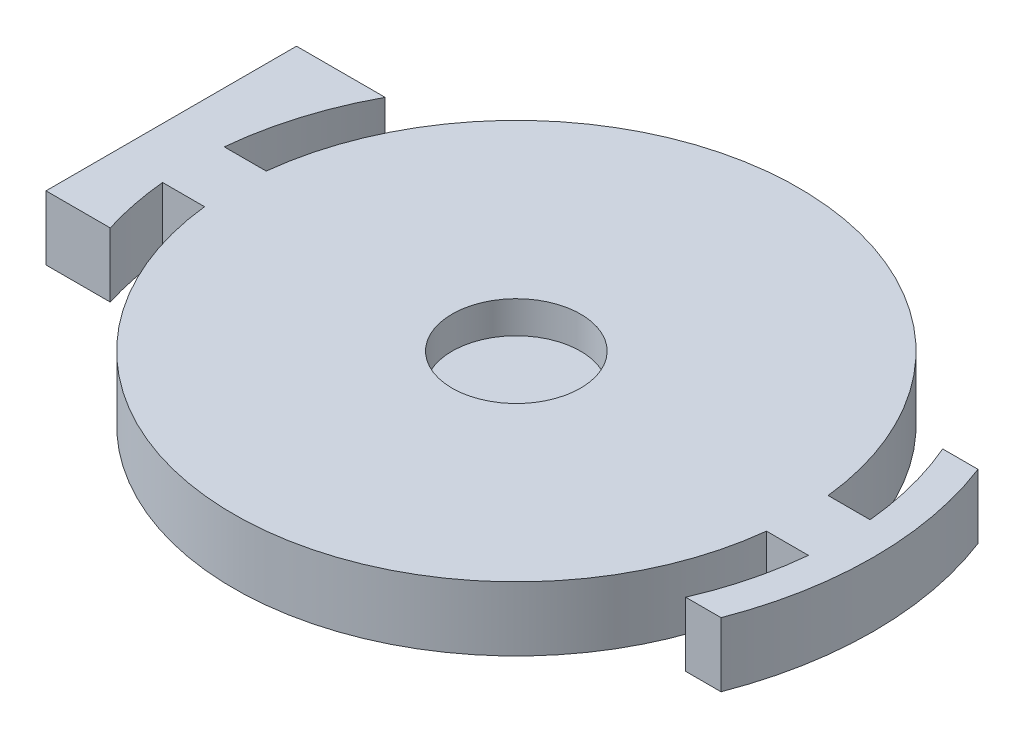
from build123d import *

# Parameters (mm, degrees)
SKETCH1_R           = 22
SKETCH1_W           = 4
SKETCH1_H           = 4.8
BOSS_EXTRUDE1_DEPTH = 5
BOSS_EXTRUDE2_DEPTH = 5
SKETCH3_R           = 5
CUT_EXTRUDE1_DEPTH  = 2.5


with BuildPart() as part:
    # Sketch1 → Boss-Extrude1 (new body)
    with BuildSketch(Plane(origin=(0, 0, 0), x_dir=(1, 0, 0), z_dir=(0, 1, 0))):
        Circle(SKETCH1_R)
        with Locations((-23.868699093, 0)):
            Rectangle(SKETCH1_W, SKETCH1_H)
        with BuildLine():
            Line((21.868699093, 2.4), (25.135681809, 2.4))
            ThreePointArc((25.135681809, 2.4), (24.45754678, 6.276217454), (23.185394109, 10))
            Line((23.185394109, 10), (25.935394109, 10))
            ThreePointArc((25.935394109, 10), (27.796486605, 0), (25.935394109, -10))
            Line((25.935394109, -10), (23.185394109, -10))
            ThreePointArc((23.185394109, -10), (24.45754678, -6.276217454), (25.135681809, -2.4))
            Line((25.135681809, -2.4), (21.868699093, -2.4))
            Line((21.868699093, -2.4), (21.868699093, 2.4))
        make_face()
    extrude(amount=BOSS_EXTRUDE1_DEPTH)

    # Sketch2 → Boss-Extrude2 (add)
    with BuildSketch(Plane(origin=(0, 5, 0), x_dir=(1, 0, 0), z_dir=(0, 1, 0))):
        with BuildLine():
            Line((-29.110423057, 12), (-22.216266563, 12))
            ThreePointArc((-22.216266563, 12), (-25.131713885, 2.441199952), (-24.110423057, -7.5))
            Line((-24.110423057, -7.5), (-29.110423057, -7.5))
            Line((-29.110423057, -7.5), (-29.110423057, 12))
        make_face()
    extrude(amount=-BOSS_EXTRUDE2_DEPTH)

    # Sketch3 → Cut-Extrude1 (cut)
    with BuildSketch(Plane(origin=(0, 5, 0), x_dir=(1, 0, 0), z_dir=(0, 1, 0))):
        Circle(SKETCH3_R)
    extrude(amount=-CUT_EXTRUDE1_DEPTH, mode=Mode.SUBTRACT)


solid = part.part
